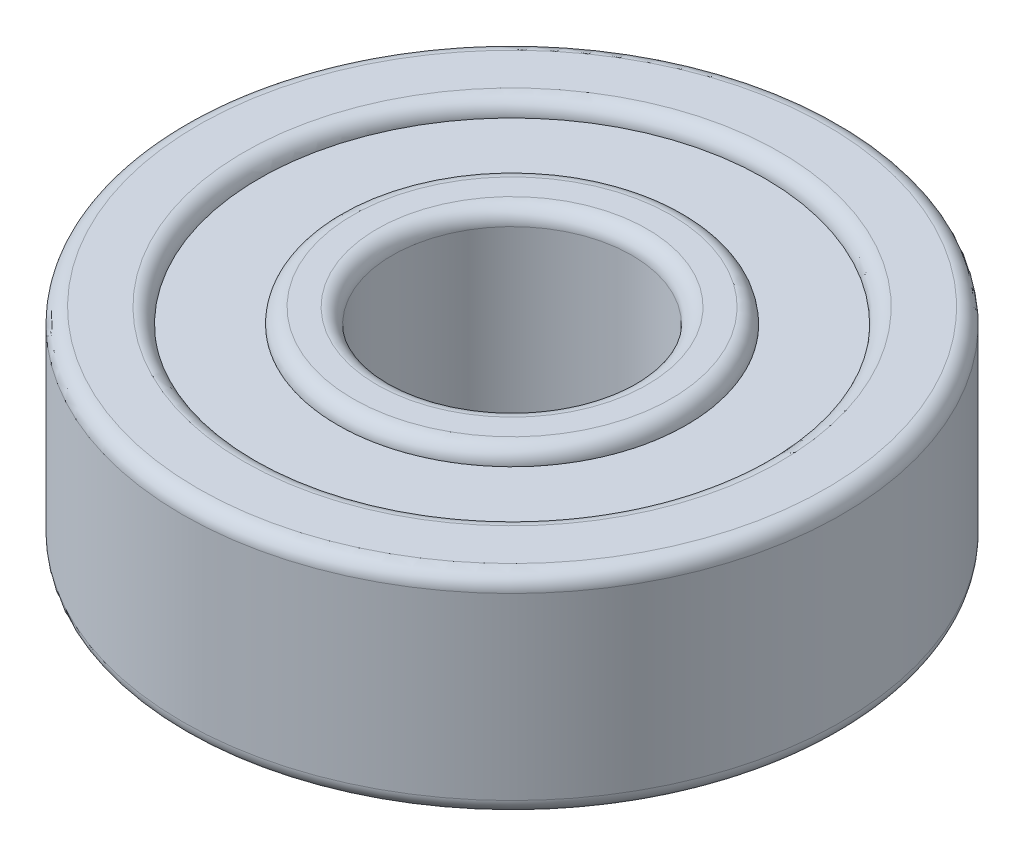
from build123d import *

# Parameters (mm, degrees)
SKETCH1_R           = 11.0000034
SKETCH1_R_2         = 4.0000047
BOSS_EXTRUDE1_DEPTH = 3.5000057
SKETCH2_R           = 8.4400009
SKETCH2_R_2         = 5.8200036
CUT_EXTRUDE1_DEPTH  = 8.0000114
SKETCH3_R           = 2.3300055
FILLET1_R           = 0.508
FILLET2_R           = 0.508
CIRPATTERN2_COUNT   = 7
BOSS_EXTRUDE4_START = 2.01495
SKETCH5_R           = 8.4400009
SKETCH5_R_2         = 5.8200036
BOSS_EXTRUDE4_DEPTH = 0.977055


with BuildPart() as part:
    # Sketch1 → Boss-Extrude1 (new body, symmetric)
    with BuildSketch(Plane(origin=(0, 0, 0), x_dir=(1, 0, 0), z_dir=(0, 1, 0))):
        Circle(SKETCH1_R)
        Circle(SKETCH1_R_2, mode=Mode.SUBTRACT)
    extrude(amount=BOSS_EXTRUDE1_DEPTH, both=True)

    # Sketch2 → Cut-Extrude1 (cut, through all)
    with BuildSketch(Plane(origin=(0, 3.5000057, 0), x_dir=(1, 0, 0), z_dir=(0, 1, 0))):
        Circle(SKETCH2_R)
        Circle(SKETCH2_R_2, mode=Mode.SUBTRACT)
    extrude(amount=-CUT_EXTRUDE1_DEPTH, mode=Mode.SUBTRACT)

    # Sketch3 → Cut-Revolve1 (revolve, cut)
    with BuildSketch(Plane(origin=(0, 0, 0), x_dir=(0, 0, -1), z_dir=(1, 0, 0))):
        with Locations((7.2700007, 0)):
            Circle(SKETCH3_R)
    revolve(axis=Axis((0, 8.468633392, 0), (0, -1, 0)), mode=Mode.SUBTRACT)

    # Fillet1
    fillet1_edges = [part.edges().sort_by_distance(p)[0] for p in [
        (-8.4400009, -3.5000057, 0),
        (-11.0000034, -3.5000057, 0),
        (-8.4400009, 3.5000057, 0),
        (-11.0000034, 3.5000057, 0),
    ]]
    fillet(fillet1_edges, radius=FILLET1_R)

    # Fillet2
    fillet2_edges = [part.edges().sort_by_distance(p)[0] for p in [
        (-5.8200036, -3.5000057, 0),
        (-5.8200036, 3.5000057, 0),
        (-4.0000047, -3.5000057, 0),
        (-4.0000047, 3.5000057, 0),
    ]]
    fillet(fillet2_edges, radius=FILLET2_R)


with BuildPart() as body_2:
    # Sketch4 → Revolve1 (revolve)
    with BuildSketch(Plane(origin=(0, 0, 0), x_dir=(0, 0, -1), z_dir=(1, 0, 0))):
        with BuildLine():
            Line((7.2700007, 2.3300055), (7.2700007, -2.3300055))
            ThreePointArc((7.2700007, -2.3300055), (9.6000062, 0), (7.2700007, 2.3300055))
        make_face()
    revolve(axis=Axis((0, 8.508066945, -7.2700007), (0, -1, 0)))


with BuildPart() as cirpattern2_1:
    # CirPattern2: pattern copy
    add(body_2.part.rotate(Axis((0, 0, 0), (0, 1, 0)), 1 * 360 / CIRPATTERN2_COUNT))


with BuildPart() as cirpattern2_2:
    # CirPattern2: pattern copy
    add(body_2.part.rotate(Axis((0, 0, 0), (0, 1, 0)), 2 * 360 / CIRPATTERN2_COUNT))


with BuildPart() as cirpattern2_3:
    # CirPattern2: pattern copy
    add(body_2.part.rotate(Axis((0, 0, 0), (0, 1, 0)), 3 * 360 / CIRPATTERN2_COUNT))


with BuildPart() as cirpattern2_4:
    # CirPattern2: pattern copy
    add(body_2.part.rotate(Axis((0, 0, 0), (0, 1, 0)), 4 * 360 / CIRPATTERN2_COUNT))


with BuildPart() as cirpattern2_5:
    # CirPattern2: pattern copy
    add(body_2.part.rotate(Axis((0, 0, 0), (0, 1, 0)), 5 * 360 / CIRPATTERN2_COUNT))


with BuildPart() as cirpattern2_6:
    # CirPattern2: pattern copy
    add(body_2.part.rotate(Axis((0, 0, 0), (0, 1, 0)), 6 * 360 / CIRPATTERN2_COUNT))


with BuildPart() as body_9:
    # Sketch5 → Boss-Extrude4 (new body)
    with BuildSketch(Plane(origin=(0, 0, 0), x_dir=(1, 0, 0), z_dir=(0, 1, 0)).offset(BOSS_EXTRUDE4_START)):
        Circle(SKETCH5_R)
        Circle(SKETCH5_R_2, mode=Mode.SUBTRACT)
    extrude(amount=BOSS_EXTRUDE4_DEPTH)


with BuildPart() as body_10:
    # Mirror1: mirrored copy
    add(body_9.part.mirror(Plane.ZX))


solid = Compound([part.part, body_2.part, cirpattern2_1.part, cirpattern2_2.part, cirpattern2_3.part, cirpattern2_4.part, cirpattern2_5.part, cirpattern2_6.part, body_9.part, body_10.part])
